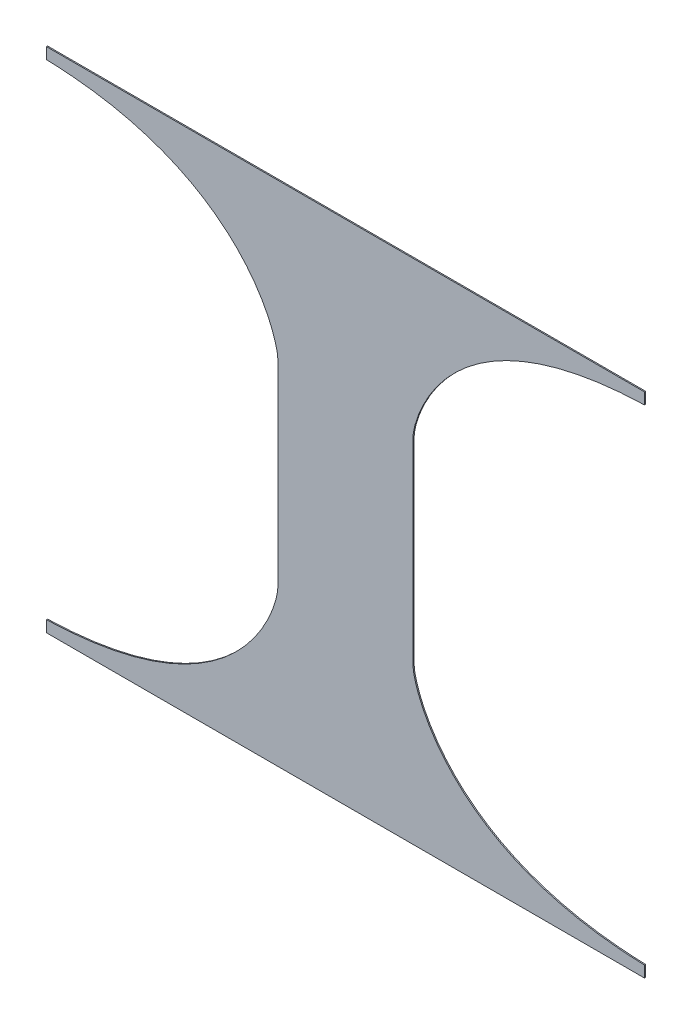
from build123d import *

# Parameters (mm, degrees)
SKETCH1_W           = 1346.2
SKETCH1_H           = 1143
BOSS_EXTRUDE1_DEPTH = 1.27
CUT_EXTRUDE1_DEPTH  = 3.54


with BuildPart() as part:
    # Sketch1 → Boss-Extrude1 (new body, symmetric)
    with BuildSketch(Plane.XY):
        Rectangle(SKETCH1_W, SKETCH1_H)
    extrude(amount=BOSS_EXTRUDE1_DEPTH, both=True)

    # Sketch2 → Cut-Extrude1 (cut, through all)
    with BuildSketch(Plane.XY.offset(1.27)):
        with BuildLine():
            Line((-673.1, 546.1), (-673.1, -546.1))
            add(Edge.make_bspline(
                [(-152.4, -224.495117073), (-152.4, -258.704669829), (-224.053162497, -532.777731838), (-673.1, -546.1)],
                knots=[0, 0, 0, 0, 1, 1, 1, 1], degree=3))
            Line((-152.4, -224.495117073), (-152.4, 224.495117073))
            add(Edge.make_bspline(
                [(-152.4, 224.495117073), (-152.4, 258.704669829), (-224.053162497, 532.777731838), (-673.1, 546.1)],
                knots=[0, 0, 0, 0, 1, 1, 1, 1], degree=3))
        make_face()
        with BuildLine():
            Line((673.1, 546.1), (673.1, -546.1))
            add(Edge.make_bspline(
                [(152.4, -224.495117073), (152.4, -258.704669829), (224.053162497, -532.777731838), (673.1, -546.1)],
                knots=[0, 0, 0, 0, 1, 1, 1, 1], degree=3))
            Line((152.4, -224.495117073), (152.4, 224.495117073))
            add(Edge.make_bspline(
                [(152.4, 224.495117073), (152.4, 258.704669829), (224.053162497, 532.777731838), (673.1, 546.1)],
                knots=[0, 0, 0, 0, 1, 1, 1, 1], degree=3))
        make_face()
    extrude(amount=-CUT_EXTRUDE1_DEPTH, mode=Mode.SUBTRACT)


solid = part.part
